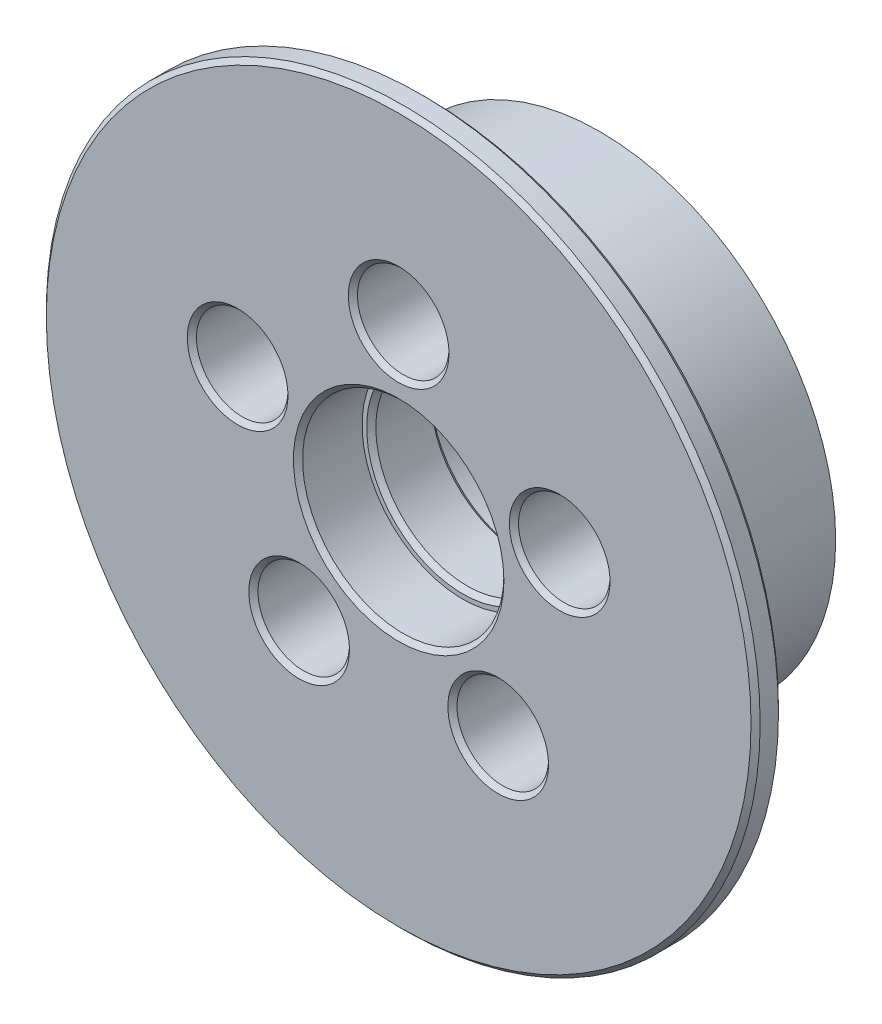
from build123d import *

# Parameters (mm, degrees)
SKETCH1_R           = 25.75
BOSS_EXTRUDE1_DEPTH = 19
SKETCH2_R           = 39
BOSS_EXTRUDE2_DEPTH = 3
SKETCH3_R           = 5
CUT_EXTRUDE1_DEPTH  = 23
SKETCH4_R           = 10
CUT_EXTRUDE2_DEPTH  = 23
SKETCH5_R           = 11
CUT_EXTRUDE3_DEPTH  = 8
SKETCH6_R           = 11
CUT_EXTRUDE4_DEPTH  = 7
CHAMFER1_SIZE       = 0.5
FILLET1_R           = 1


with BuildPart() as part:
    # Sketch1 → Boss-Extrude1 (new body)
    with BuildSketch(Plane.XY):
        Circle(SKETCH1_R)
    extrude(amount=BOSS_EXTRUDE1_DEPTH)

    # Sketch2 → Boss-Extrude2 (add)
    with BuildSketch(Plane.XY.offset(19)):
        Circle(SKETCH2_R)
    extrude(amount=BOSS_EXTRUDE2_DEPTH)

    # Sketch3 → Cut-Extrude1 (cut, through all)
    with BuildSketch(Plane(origin=(0, 0, 0), x_dir=(-1, 0, 0), z_dir=(0, 0, -1))):
        with Locations((0, 18.5)):
            Circle(SKETCH3_R)
        with Locations((17.594545551, 5.716814396)):
            Circle(SKETCH3_R)
        with Locations((10.874027167, -14.966814396)):
            Circle(SKETCH3_R)
        with Locations((-10.874027167, -14.966814396)):
            Circle(SKETCH3_R)
        with Locations((-17.594545551, 5.716814396)):
            Circle(SKETCH3_R)
    extrude(amount=-CUT_EXTRUDE1_DEPTH, mode=Mode.SUBTRACT)

    # Sketch4 → Cut-Extrude2 (cut, through all)
    with BuildSketch(Plane(origin=(0, 0, 0), x_dir=(-1, 0, 0), z_dir=(0, 0, -1))):
        Circle(SKETCH4_R)
    extrude(amount=-CUT_EXTRUDE2_DEPTH, mode=Mode.SUBTRACT)

    # Sketch5 → Cut-Extrude3 (cut)
    with BuildSketch(Plane(origin=(0, 0, 0), x_dir=(-1, 0, 0), z_dir=(0, 0, -1))):
        Circle(SKETCH5_R)
    extrude(amount=-CUT_EXTRUDE3_DEPTH, mode=Mode.SUBTRACT)

    # Sketch6 → Cut-Extrude4 (cut)
    with BuildSketch(Plane.XY.offset(22)):
        Circle(SKETCH6_R)
    extrude(amount=-CUT_EXTRUDE4_DEPTH, mode=Mode.SUBTRACT)

    # Chamfer1
    chamfer1_edges = [part.edges().sort_by_distance(p)[0] for p in [
        (5, 18.5, 22),
        (-12.594545551, 5.716814396, 22),
        (-5.874027167, -14.966814396, 22),
        (15.874027167, -14.966814396, 22),
        (22.594545551, 5.716814396, 22),
        (11, 0, 0),
        (10, 0, 8),
        (-11, 0, 22),
        (10, 0, 15),
        (-39, 0, 19),
        (-39, 0, 22),
    ]]
    chamfer(chamfer1_edges, length=CHAMFER1_SIZE)

    # Fillet1
    fillet1_edges = [part.edges().sort_by_distance(p)[0] for p in [
        (5, 18.5, 0),
        (-12.594545551, 5.716814396, 0),
        (-5.874027167, -14.966814396, 0),
        (15.874027167, -14.966814396, 0),
        (22.594545551, 5.716814396, 0),
    ]]
    fillet(fillet1_edges, radius=FILLET1_R)


solid = part.part
